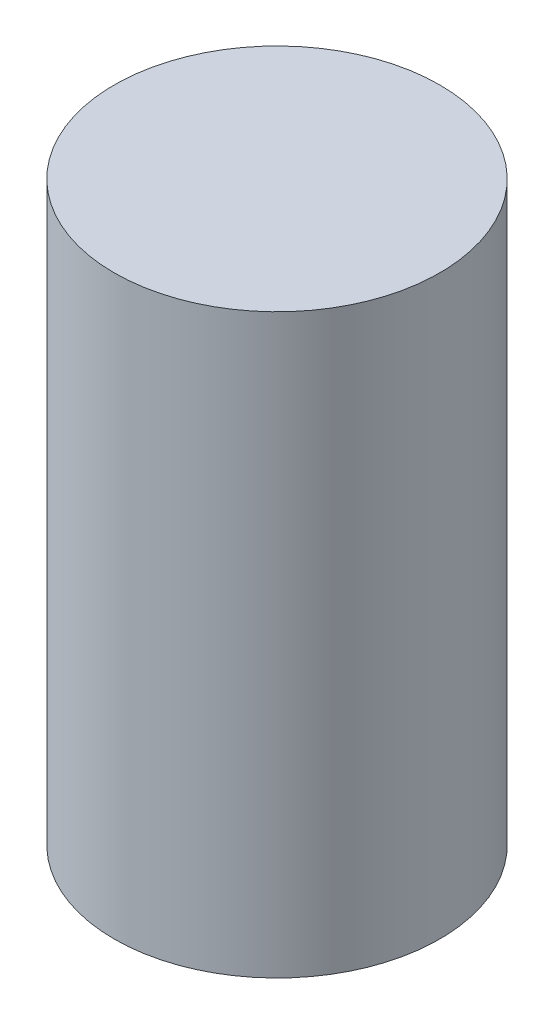
from build123d import *

# Parameters (mm, degrees)
SKETCH1_R      = 45.72
EXTRUDE1_DEPTH = 162.052


with BuildPart() as part:
    # Sketch1 → Extrude1 (new body)
    with BuildSketch(Plane(origin=(0, 0, 0), x_dir=(1, 0, 0), z_dir=(0, 1, 0))):
        Circle(SKETCH1_R)
    extrude(amount=EXTRUDE1_DEPTH)


solid = part.part
